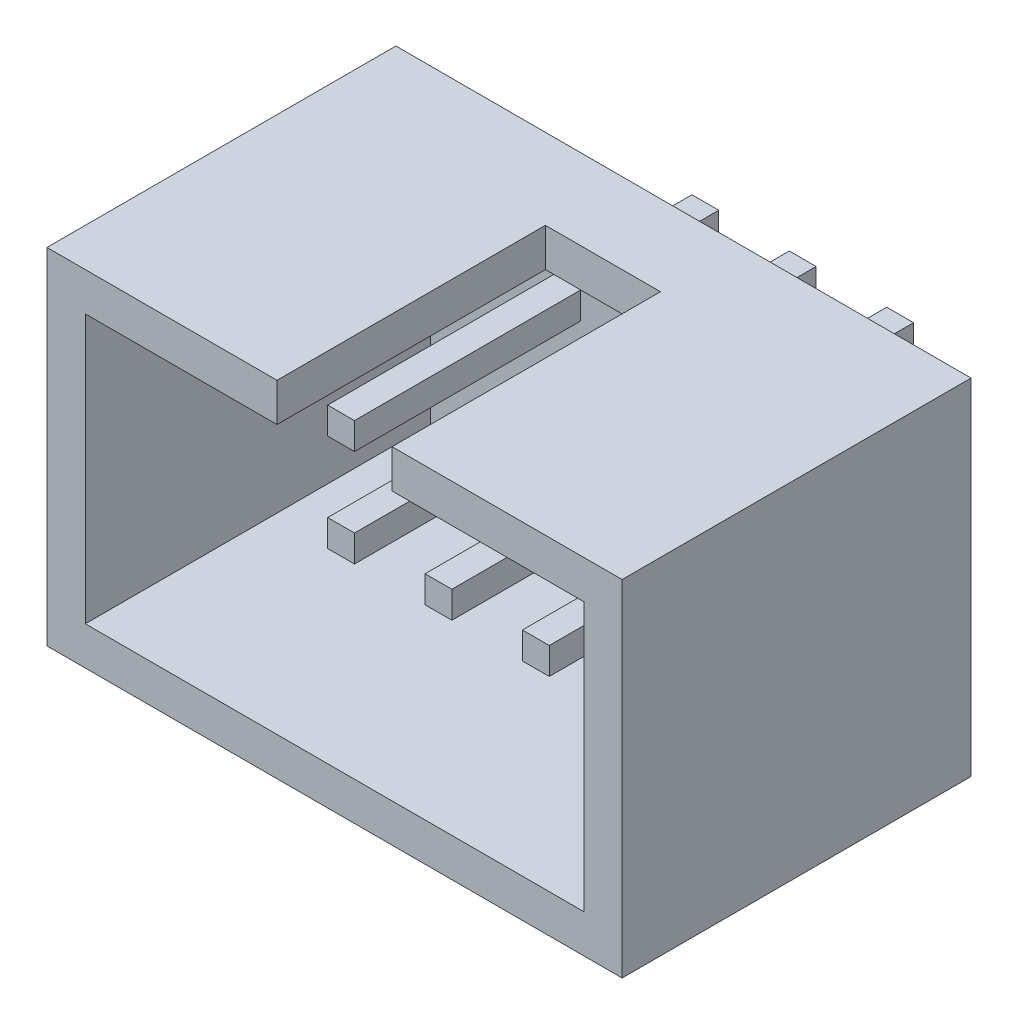
from build123d import *

# Parameters (mm, degrees)
CROQUIS1_W                   = 15
CROQUIS1_H                   = 9
CROQUIS1_W_2                 = 13
CROQUIS1_H_2                 = 7
SALIENTE_EXTRUIR1_DEPTH      = 9
CROQUIS2_W                   = 15
CROQUIS2_H                   = 9
SALIENTE_EXTRUIR2_DEPTH      = 0.1
CROQUIS3_W                   = 3
CROQUIS3_H                   = 3.407555274
CORTAR_EXTRUIR1_DEPTH        = 7
CROQUIS4_W                   = 0.7
CROQUIS4_H                   = 0.7
SALIENTE_EXTRUIR3_DEPTH      = 3.5
SALIENTE_EXTRUIR3_DEPTH_BACK = 6


with BuildPart() as part:
    # Croquis1 → Saliente-Extruir1 (new body)
    with BuildSketch(Plane.XY):
        Rectangle(CROQUIS1_W, CROQUIS1_H)
        Rectangle(CROQUIS1_W_2, CROQUIS1_H_2, mode=Mode.SUBTRACT)
    extrude(amount=SALIENTE_EXTRUIR1_DEPTH)

    # Croquis2 → Saliente-Extruir2 (add)
    with BuildSketch(Plane(origin=(0, 0, 0), x_dir=(-1, 0, 0), z_dir=(0, 0, -1))):
        Rectangle(CROQUIS2_W, CROQUIS2_H)
    extrude(amount=SALIENTE_EXTRUIR2_DEPTH)

    # Croquis3 → Cortar-Extruir1 (cut)
    with BuildSketch(Plane.XY.offset(9)):
        with Locations((0, 3.5)):
            Rectangle(CROQUIS3_W, CROQUIS3_H)
    extrude(amount=-CORTAR_EXTRUIR1_DEPTH, mode=Mode.SUBTRACT)

    # Croquis4 → Saliente-Extruir3 (add, two sides)
    with BuildSketch(Plane(origin=(0, 0, -0.1), x_dir=(-1, 0, 0), z_dir=(0, 0, -1))) as saliente_extruir3_sk:
        with Locations((-2.15, 1.15)):
            Rectangle(CROQUIS4_W, CROQUIS4_H)
        with Locations((0.39, 1.15)):
            Rectangle(CROQUIS4_W, CROQUIS4_H)
        with Locations((2.93, 1.15)):
            Rectangle(CROQUIS4_W, CROQUIS4_H)
        with Locations((0.39, -1.39)):
            Rectangle(CROQUIS4_W, CROQUIS4_H)
        with Locations((2.93, -1.39)):
            Rectangle(CROQUIS4_W, CROQUIS4_H)
        with Locations((-2.15, -1.39)):
            Rectangle(CROQUIS4_W, CROQUIS4_H)
    extrude(amount=SALIENTE_EXTRUIR3_DEPTH)
    extrude(saliente_extruir3_sk.sketch, amount=-SALIENTE_EXTRUIR3_DEPTH_BACK)


solid = part.part
